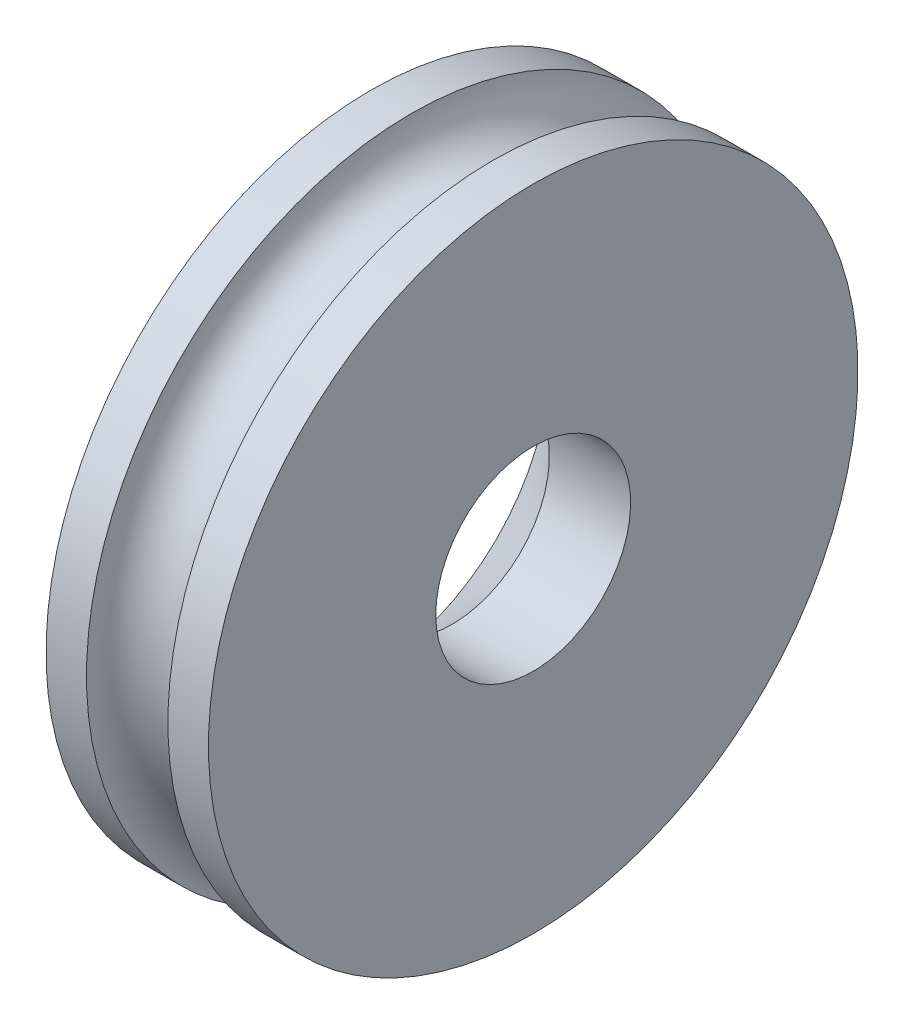
from build123d import *

# Parameters (mm, degrees)
FORMSENKUNG_F_R_M2_LINSENSENKSCHRAUBE_MI_D           = 2.4
FORMSENKUNG_F_R_M2_LINSENSENKSCHRAUBE_MI_DEPTH       = 5
FORMSENKUNG_F_R_M2_LINSENSENKSCHRAUBE_MI_CSINK_D     = 4.4
FORMSENKUNG_F_R_M2_LINSENSENKSCHRAUBE_MI_CSINK_ANGLE = 90
FORMSENKUNG_F_R_M2_LINSENSENKSCHRAUBE_MI_TIP         = 0.721032743


with BuildPart() as part:
    # Skizze1 → Rotation1 (revolve)
    with BuildSketch(Plane.XY):
        with BuildLine():
            Line((0, 0), (0, 4))
            Line((0, 4), (-0.499279021, 4))
            ThreePointArc((-0.499279021, 4), (-1.000662513, 3.498616507), (-1.502046006, 4))
            Line((-1.502046006, 4), (-2, 4))
            Line((-2, 4), (-2, 0))
            Line((-2, 0), (0, 0))
        make_face()
    revolve(axis=Axis((0, 0, 0), (-1, 0, 0)))

    # Formsenkung für M2 Linsensenkschraube mit Schlitz1
    with Locations(Plane.ZY.offset(2)):
        with Locations((0, 0)):
            CounterSinkHole(FORMSENKUNG_F_R_M2_LINSENSENKSCHRAUBE_MI_D / 2, FORMSENKUNG_F_R_M2_LINSENSENKSCHRAUBE_MI_CSINK_D / 2, depth=FORMSENKUNG_F_R_M2_LINSENSENKSCHRAUBE_MI_DEPTH, counter_sink_angle=FORMSENKUNG_F_R_M2_LINSENSENKSCHRAUBE_MI_CSINK_ANGLE)
            with Locations((0, 0, -(FORMSENKUNG_F_R_M2_LINSENSENKSCHRAUBE_MI_DEPTH + FORMSENKUNG_F_R_M2_LINSENSENKSCHRAUBE_MI_TIP / 2))):  # 118° drill point
                Cone(0, FORMSENKUNG_F_R_M2_LINSENSENKSCHRAUBE_MI_D / 2, FORMSENKUNG_F_R_M2_LINSENSENKSCHRAUBE_MI_TIP, mode=Mode.SUBTRACT)


solid = part.part
